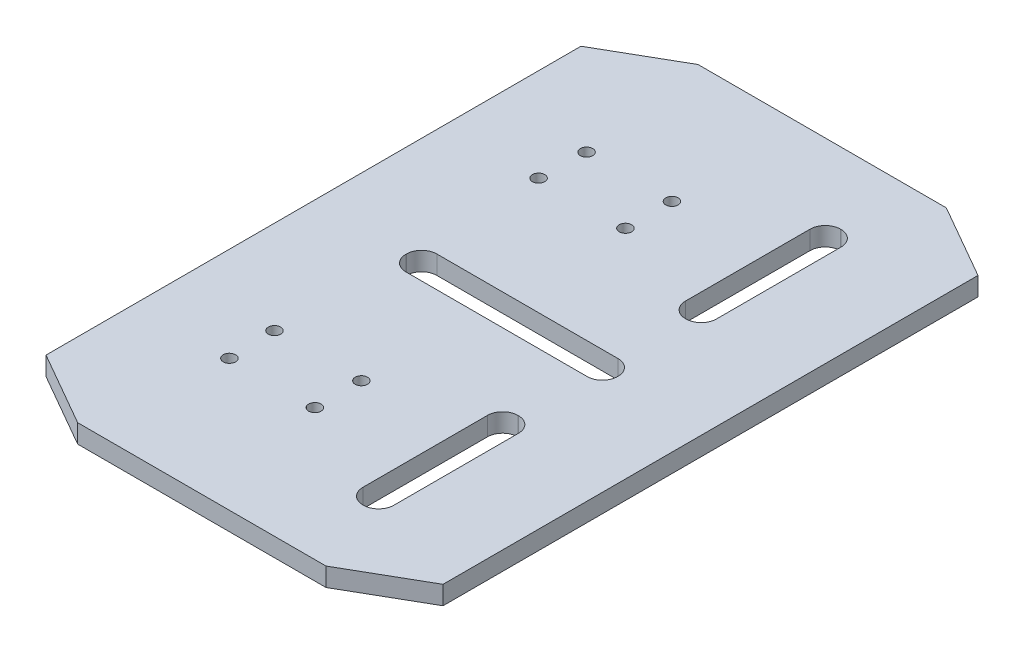
from build123d import *

# Parameters (mm, degrees)
BOSS_EXTRUDE1_DEPTH = 3
CUT_EXTRUDE2_DEPTH  = 10
SKETCH7_R           = 1
CUT_EXTRUDE3_DEPTH  = 11.5


with BuildPart() as part:
    # Sketch1 → Boss-Extrude1 (new body)
    with BuildSketch(Plane(origin=(0, 0, 0), x_dir=(1, 0, 0), z_dir=(0, 1, 0))):
        Polygon((-32, -43.117707706), (-20.011895516, -50), (20.011895516, -50), (32, -43.117707706), (32, 43.117707706), (20.011895516, 50), (-20.011895516, 50), (-32, 43.117707706), align=None)
    extrude(amount=BOSS_EXTRUDE1_DEPTH)

    # Sketch5 → Cut-Extrude2 (cut)
    with BuildSketch(Plane(origin=(0, 3, 0), x_dir=(1, 0, 0), z_dir=(0, 1, 0))):
        with BuildLine():
            Line((-14.620176413, -2.5), (14.620176413, -2.5))
            ThreePointArc((14.620176413, -2.5), (16.352588027, -1.782411614), (17.070176413, -0.05))
            Line((17.070176413, -0.05), (17.070176413, 0.05))
            ThreePointArc((17.070176413, 0.05), (16.352588027, 1.782411614), (14.620176413, 2.5))
            Line((14.620176413, 2.5), (-14.620176413, 2.5))
            ThreePointArc((-14.620176413, 2.5), (-16.352588027, 1.782411614), (-17.070176413, 0.05))
            Line((-17.070176413, 0.05), (-17.070176413, -0.05))
            ThreePointArc((-17.070176413, -0.05), (-16.352588027, -1.782411614), (-14.620176413, -2.5))
        make_face()
        with BuildLine():
            Line((14.45, -38.5), (14.55, -38.5))
            ThreePointArc((14.55, -38.5), (16.282411614, -37.782411614), (17, -36.05))
            Line((17, -36.05), (17, -15.95))
            ThreePointArc((17, -15.95), (16.282411614, -14.217588386), (14.55, -13.5))
            Line((14.55, -13.5), (14.45, -13.5))
            ThreePointArc((14.45, -13.5), (12.717588386, -14.217588386), (12, -15.95))
            Line((12, -15.95), (12, -36.05))
            ThreePointArc((12, -36.05), (12.717588386, -37.782411614), (14.45, -38.5))
        make_face()
        with BuildLine():
            Line((14.45, 13.5), (14.55, 13.5))
            ThreePointArc((14.55, 13.5), (16.282411614, 14.217588386), (17, 15.95))
            Line((17, 15.95), (17, 36.05))
            ThreePointArc((17, 36.05), (16.282411614, 37.782411614), (14.55, 38.5))
            Line((14.55, 38.5), (14.45, 38.5))
            ThreePointArc((14.45, 38.5), (12.717588386, 37.782411614), (12, 36.05))
            Line((12, 36.05), (12, 15.95))
            ThreePointArc((12, 15.95), (12.717588386, 14.217588386), (14.45, 13.5))
        make_face()
    extrude(amount=-CUT_EXTRUDE2_DEPTH, mode=Mode.SUBTRACT)

    # Sketch7 → Cut-Extrude3 (cut)
    with BuildSketch(Plane(origin=(0, 3, 0), x_dir=(1, 0, 0), z_dir=(0, 1, 0))):
        with Locations((-3, 28.785)):
            Circle(SKETCH7_R)
        with Locations((-3, 21.285)):
            Circle(SKETCH7_R)
        with Locations((-17, 21.285)):
            Circle(SKETCH7_R)
        with Locations((-16.76760758, 28.785)):
            Circle(SKETCH7_R)
    cut_extrude3 = extrude(amount=-CUT_EXTRUDE3_DEPTH, mode=Mode.SUBTRACT)

    # Mirror1: Cut-Extrude3 across plane
    add(cut_extrude3.mirror(Plane(origin=(0, 0, 0), x_dir=(1, 0, 0), z_dir=(0, 0, -1))), mode=Mode.SUBTRACT)


solid = part.part
